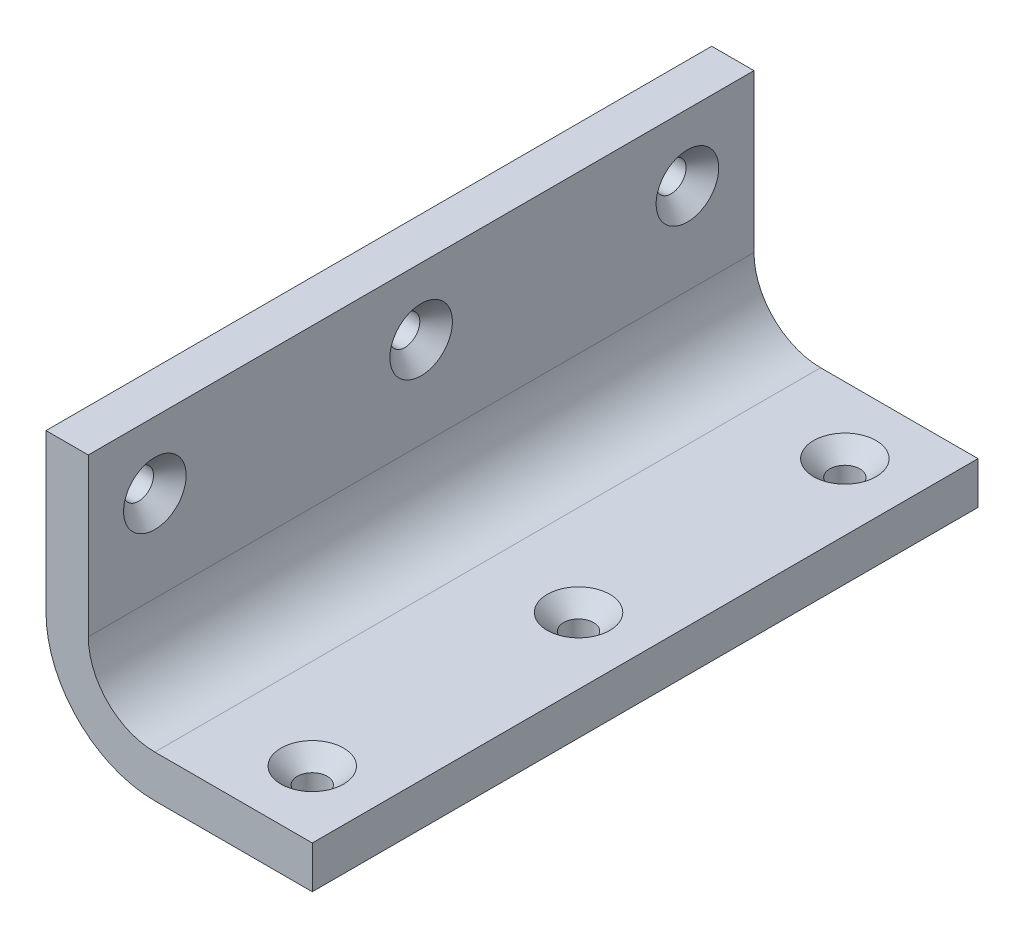
from build123d import *

# Parameters (mm, degrees)
BOSS_EXTRUDE1_DEPTH                             = 100
CSK_FOR_M4_FLAT_HEAD_MACHINE_SCREW1_D           = 4.5
CSK_FOR_M4_FLAT_HEAD_MACHINE_SCREW1_CSINK_D     = 9.4
CSK_FOR_M4_FLAT_HEAD_MACHINE_SCREW1_CSINK_ANGLE = 90
CSK_FOR_M4_FLAT_HEAD_MACHINE_SCREW4_D           = 4.5
CSK_FOR_M4_FLAT_HEAD_MACHINE_SCREW4_CSINK_D     = 9.4
CSK_FOR_M4_FLAT_HEAD_MACHINE_SCREW4_CSINK_ANGLE = 90


with BuildPart() as part:
    # Sketch1 → Boss-Extrude1 (new body)
    with BuildSketch(Plane.XY):
        with BuildLine():
            Line((0, 40), (0, 16.35))
            ThreePointArc((0, 16.35), (4.788804128, 4.788804128), (16.35, 0))
            Line((16.35, 0), (40, 0))
            Line((40, 0), (40, 6.35))
            Line((40, 6.35), (16.35, 6.35))
            ThreePointArc((16.35, 6.35), (9.278932188, 9.278932188), (6.35, 16.35))
            Line((6.35, 16.35), (6.35, 40))
            Line((6.35, 40), (0, 40))
        make_face()
    extrude(amount=BOSS_EXTRUDE1_DEPTH)

    # CSK for M4 Flat Head Machine Screw1 (through all)
    with Locations(Plane(origin=(0, 6.35, 0), x_dir=(1, 0, 0), z_dir=(0, 1, 0))):
        with Locations((30, -90), (30, -50), (30, -10)):
            CounterSinkHole(CSK_FOR_M4_FLAT_HEAD_MACHINE_SCREW1_D / 2, CSK_FOR_M4_FLAT_HEAD_MACHINE_SCREW1_CSINK_D / 2, counter_sink_angle=CSK_FOR_M4_FLAT_HEAD_MACHINE_SCREW1_CSINK_ANGLE)

    # CSK for M4 Flat Head Machine Screw4 (through all)
    with Locations(Plane(origin=(6.35, 0, 0), x_dir=(0, -1, 0), z_dir=(1, 0, 0))):
        with Locations((-30, -90), (-30, -50), (-30, -10)):
            CounterSinkHole(CSK_FOR_M4_FLAT_HEAD_MACHINE_SCREW4_D / 2, CSK_FOR_M4_FLAT_HEAD_MACHINE_SCREW4_CSINK_D / 2, counter_sink_angle=CSK_FOR_M4_FLAT_HEAD_MACHINE_SCREW4_CSINK_ANGLE)


solid = part.part
